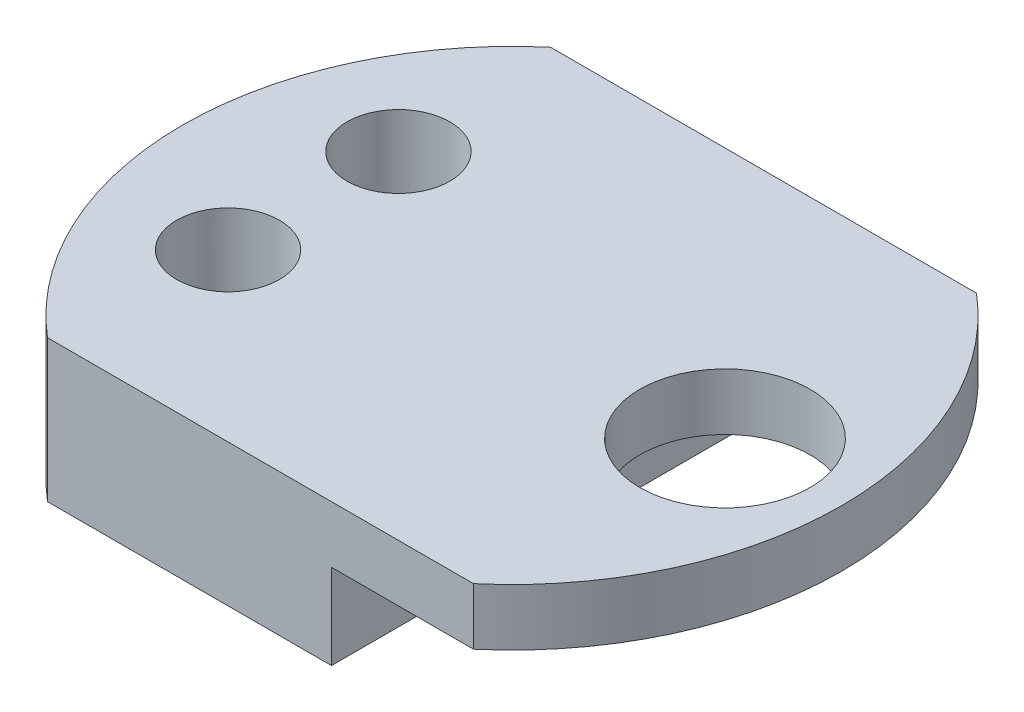
from build123d import *

# Parameters (mm, degrees)
BOSS_EXTRUDE2_DEPTH = 6.35
SKETCH4_R           = 2.3
SKETCH4_R_2         = 3.81
CUT_EXTRUDE1_DEPTH  = 12.7
CUT_EXTRUDE2_DEPTH  = 3.81


with BuildPart() as part:
    # Sketch3 → Boss-Extrude2 (new body)
    with BuildSketch(Plane(origin=(0, 0, 0), x_dir=(1, 0, 0), z_dir=(0, 1, 0))):
        with BuildLine():
            Line((-9.525, 11.25), (9.525, 11.25))
            ThreePointArc((9.525, 11.25), (14.740696218, 0), (9.525, -11.25))
            Line((9.525, -11.25), (-9.525, -11.25))
            ThreePointArc((-9.525, -11.25), (-14.740696218, 0), (-9.525, 11.25))
        make_face()
    extrude(amount=BOSS_EXTRUDE2_DEPTH)

    # Sketch4 → Cut-Extrude1 (cut)
    with BuildSketch(Plane(origin=(0, 6.35, 0), x_dir=(1, 0, 0), z_dir=(0, 1, 0))):
        with Locations((-8.89, 3.81)):
            Circle(SKETCH4_R)
        with Locations((-8.89, -3.81)):
            Circle(SKETCH4_R)
        with Locations((9.525, 0)):
            Circle(SKETCH4_R_2)
    extrude(amount=-CUT_EXTRUDE1_DEPTH, mode=Mode.SUBTRACT)

    # Sketch5 → Cut-Extrude2 (cut)
    with BuildSketch(Plane.XZ):
        with BuildLine():
            Line((9.525, 11.25), (3.175, 11.25))
            Line((3.175, 11.25), (3.175, -11.25))
            Line((3.175, -11.25), (9.525, -11.25))
            ThreePointArc((9.525, -11.25), (14.740696218, 0), (9.525, 11.25))
        make_face()
    extrude(amount=-CUT_EXTRUDE2_DEPTH, mode=Mode.SUBTRACT)


solid = part.part
